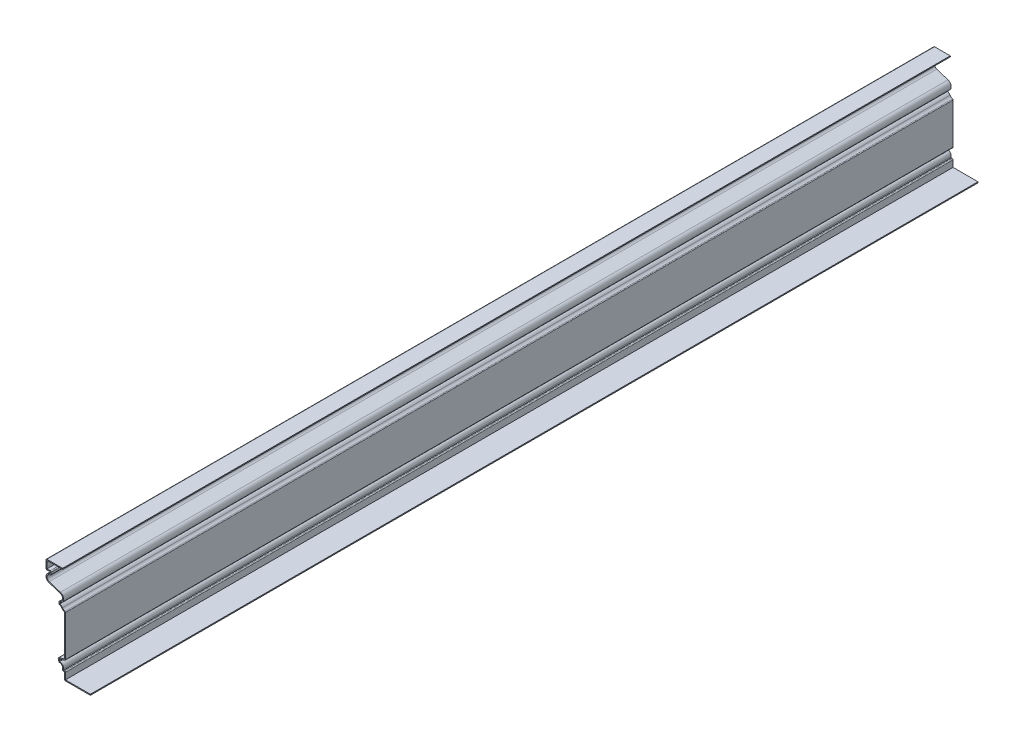
from build123d import *

# Parameters (mm, degrees)
EXTRUDE_THIN1_DEPTH = 1524
FILLET1_R           = 1.651


with BuildPart() as part:
    # Sketch1 → Extrude-Thin1 (new body)
    with BuildSketch(Plane.XY):
        with BuildLine():
            Line((0, 0), (-44.45, 0))
            Line((-44.45, 0), (-44.45, 12.7))
            Line((-44.45, 12.7), (-47.625, 12.7))
            Line((-47.625, 12.7), (-47.625, 16.725738686))
            ThreePointArc((-47.625, 16.725738686), (-49.543830542, 20.925868892), (-53.975, 22.225))
            Line((-53.975, 22.225), (-55.5625, 28.575))
            Line((-55.5625, 28.575), (-44.45, 31.75))
            Line((-44.45, 31.75), (-44.45, 101.6))
            ThreePointArc((-44.45, 101.6), (-47.130906672, 103.132600901), (-49.268021434, 105.361696367))
            ThreePointArc((-49.268021434, 105.361696367), (-51.342554678, 107.440960699), (-53.975, 108.74375))
            Line((-53.975, 108.74375), (-53.975, 113.50625))
            ThreePointArc((-53.975, 113.50625), (-47.702285259, 118.868550766), (-52.023643923, 125.898990228))
            Line((-52.023643923, 125.898990228), (-71.251525587, 132.108167244))
            ThreePointArc((-71.251525587, 132.108167244), (-76.113054084, 140.017411638), (-69.05625, 146.05))
            Line((-69.05625, 146.05), (-69.05625, 149.225))
            Line((-69.05625, 149.225), (-76.2, 149.225))
            Line((-76.2, 149.225), (-76.2, 165.1))
            Line((-76.2, 165.1), (-47.625, 165.1))
            Line((-47.625, 165.1), (-47.625, 163.449))
            Line((-47.625, 163.449), (-74.549, 163.449))
            Line((-74.549, 163.449), (-74.549, 150.876))
            Line((-74.549, 150.876), (-67.40525, 150.876))
            Line((-67.40525, 150.876), (-67.40525, 144.145))
            ThreePointArc((-67.40525, 144.145), (-74.289142714, 140.575721893), (-70.744173007, 133.679279703))
            Line((-70.744173007, 133.679279703), (-51.516291343, 127.470102687))
            ThreePointArc((-51.516291343, 127.470102687), (-45.984921685, 119.438339092), (-52.324, 112.027444216))
            Line((-52.324, 112.027444216), (-52.324, 109.890107647))
            ThreePointArc((-52.324, 109.890107647), (-49.883528392, 108.403175809), (-47.925046246, 106.322018525))
            ThreePointArc((-47.925046246, 106.322018525), (-45.671413632, 104.108692809), (-42.799, 102.794573098))
            Line((-42.799, 102.794573098), (-42.799, 30.504648368))
            Line((-42.799, 30.504648368), (-53.573493562, 27.426221636))
            Line((-53.573493562, 27.426221636), (-52.696098481, 23.916641311))
            ThreePointArc((-52.696098481, 23.916641311), (-47.916220995, 21.647519069), (-45.974, 16.725738686))
            Line((-45.974, 16.725738686), (-45.974, 14.351))
            Line((-45.974, 14.351), (-42.799, 14.351))
            Line((-42.799, 14.351), (-42.799, 1.651))
            Line((-42.799, 1.651), (0, 1.651))
            Line((0, 1.651), (0, 0))
        make_face()
    extrude(amount=-EXTRUDE_THIN1_DEPTH)

    # Fillet1
    fillet1_edges = [part.edges().sort_by_distance(p)[0] for p in [
        (-67.40525, 150.876, -762),
        (-67.40525, 144.145, -762),
        (-42.799, 102.794573098, -762),
        (-42.799, 30.504648368, -762),
        (-42.799, 14.351, -762),
        (-44.45, 0, -762),
        (-47.625, 12.7, -762),
        (-53.975, 22.225, -762),
        (-55.5625, 28.575, -762),
        (-53.975, 108.74375, -762),
        (-53.975, 113.50625, -762),
        (-76.2, 149.225, -762),
        (-76.2, 165.1, -762),
    ]]
    fillet(fillet1_edges, radius=FILLET1_R)


solid = part.part
